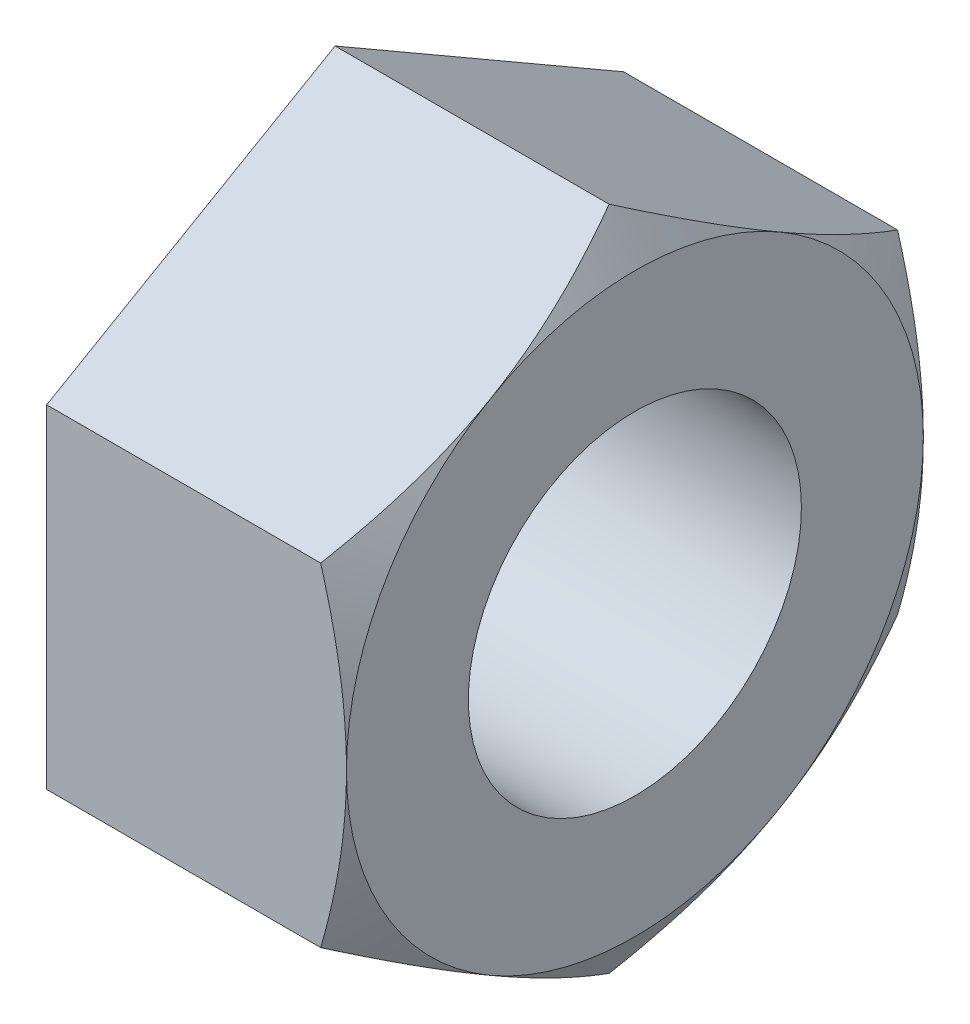
from build123d import *

# Parameters (mm, degrees)
BOSS_EXTRUDE1_DEPTH = 21.6
CUT_EXTRUDE1_REACH  = 23.6
SKETCH2_R           = 12
SKETCH3_OUTSIDE_W   = 135.272
SKETCH3_OUTSIDE_H   = 141.702
SKETCH3_OUTSIDE_R   = 20.784609691
CUT_EXTRUDE2_DEPTH  = 22.6
CUT_EXTRUDE2_TAPER  = 60


with BuildPart() as part:
    # Sketch1 → Boss-Extrude1 (new body)
    with BuildSketch(Plane(origin=(0, 0, 0), x_dir=(0, 0, -1), z_dir=(1, 0, 0))):
        Polygon((0, 24), (-20.784609691, 12), (-20.784609691, -12), (0, -24), (20.784609691, -12), (20.784609691, 12), align=None)
    extrude(amount=-BOSS_EXTRUDE1_DEPTH)

    # Sketch2 → Cut-Extrude1 (cut, up to next)
    with BuildSketch(Plane(origin=(0, 0, 0), x_dir=(0, 0, -1), z_dir=(1, 0, 0)), mode=Mode.PRIVATE) as cut_extrude1_sk1:
        Circle(SKETCH2_R)
    cut_extrude1_tool1 = extrude(cut_extrude1_sk1.sketch, amount=-CUT_EXTRUDE1_REACH, mode=Mode.PRIVATE) & part.part
    add(cut_extrude1_tool1.solids().sort_by_distance((0, 0, 0))[0], mode=Mode.SUBTRACT)

    # Sketch3 outside → Cut-Extrude2 (cut, through all)
    with BuildSketch(Plane(origin=(0, 0, 0), x_dir=(0, 0, -1), z_dir=(1, 0, 0))):
        Rectangle(SKETCH3_OUTSIDE_W, SKETCH3_OUTSIDE_H)
        Circle(SKETCH3_OUTSIDE_R, mode=Mode.SUBTRACT)
    extrude(amount=-CUT_EXTRUDE2_DEPTH, taper=CUT_EXTRUDE2_TAPER, mode=Mode.SUBTRACT)


solid = part.part
